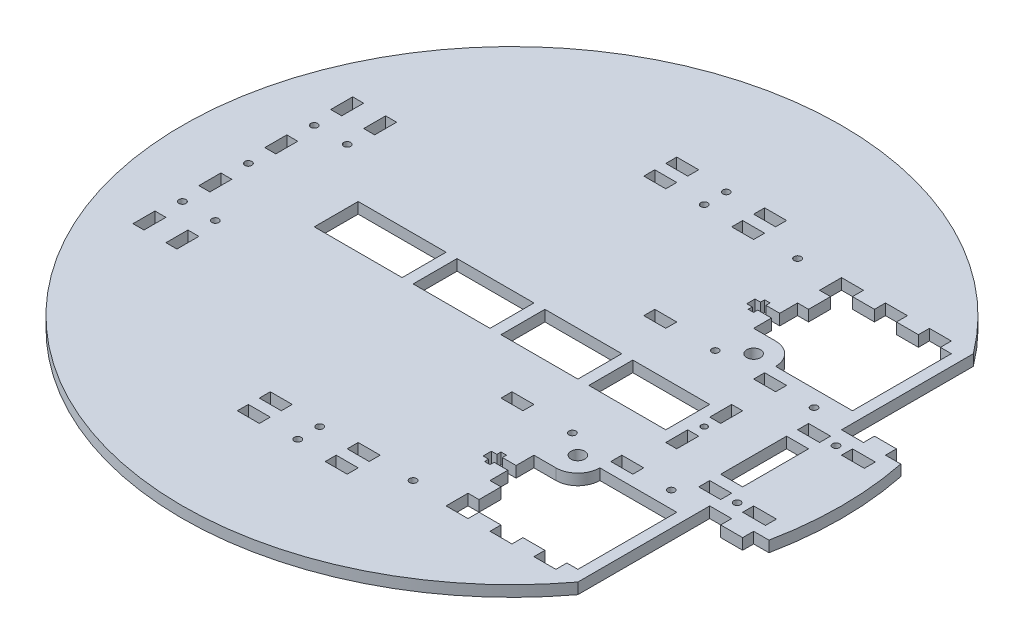
from build123d import *

# Parameters (mm, degrees)
SKETCH2_R           = 190.5
BOSS_EXTRUDE1_DEPTH = 6.35
SKETCH5_R           = 2
SKETCH5_R_2         = 2.032
SKETCH5_W           = 12.7
SKETCH5_H           = 6.35
CUT_EXTRUDE1_DEPTH  = 6.35
SKETCH6_R           = 2.032
SKETCH6_W           = 6.35
SKETCH6_H           = 12.7
CUT_EXTRUDE2_DEPTH  = 6.35
CUT_EXTRUDE3_START  = -6.35
SKETCH7_R           = 4.0005
CUT_EXTRUDE3_DEPTH  = 6.35
SKETCH11_R          = 2
SKETCH11_W          = 12.7
SKETCH11_H          = 6.35
CUT_EXTRUDE8_DEPTH  = 6.35
SKETCH12_R          = 2
SKETCH12_R_2        = 1.748762148
SKETCH12_W          = 12.7
SKETCH12_H          = 38.1
SKETCH12_H_2        = 6.35
SKETCH12_W_2        = 13.191185603
SKETCH12_W_3        = 6.35
SKETCH12_H_3        = 12.7
CUT_EXTRUDE9_DEPTH  = 6.35
CUT_EXTRUDE10_DEPTH = 6.35
SKETCH14_W          = 44.45
SKETCH14_H          = 25.4
SKETCH14_W_2        = 50.8
CUT_EXTRUDE12_DEPTH = 6.35
SKETCH6_3_R         = 2.032
SKETCH6_3_R_2       = 2
SKETCH6_3_W         = 6.35
SKETCH6_3_H         = 12.7
CUT_EXTRUDE13_DEPTH = 6.35
SKETCH17_R          = 2
SKETCH17_W          = 6.35
SKETCH17_H          = 12.7
CUT_EXTRUDE14_DEPTH = 6.35


with BuildPart() as part:
    # Sketch2 → Boss-Extrude1 (new body)
    with BuildSketch(Plane(origin=(0, 0, 0), x_dir=(1, 0, 0), z_dir=(0, 1, 0))):
        Circle(SKETCH2_R)
    extrude(amount=BOSS_EXTRUDE1_DEPTH)

    # Sketch5 → Cut-Extrude1 (cut)
    with BuildSketch(Plane(origin=(0, 6.35, 0), x_dir=(1, 0, 0), z_dir=(0, 1, 0))):
        with Locations((0, 123.825)):
            Circle(SKETCH5_R)
        with Locations((0, 111.125)):
            Circle(SKETCH5_R)
        with Locations((0, -111.125)):
            Circle(SKETCH5_R)
        with Locations((0, -123.825)):
            Circle(SKETCH5_R)
        with Locations((53.975, 111.125)):
            Circle(SKETCH5_R)
        with Locations((53.975, -111.125)):
            Circle(SKETCH5_R_2)
        with Locations((25.4, 111.125)):
            Rectangle(SKETCH5_W, SKETCH5_H)
        with Locations((25.4, 123.825)):
            Rectangle(SKETCH5_W, SKETCH5_H)
        with Locations((-25.4, 111.125)):
            Rectangle(SKETCH5_W, SKETCH5_H)
        with Locations((-25.4, 123.825)):
            Rectangle(SKETCH5_W, SKETCH5_H)
        with Locations((25.4, -111.125)):
            Rectangle(SKETCH5_W, SKETCH5_H)
        with Locations((-25.4, -111.125)):
            Rectangle(SKETCH5_W, SKETCH5_H)
        with Locations((-25.4, -123.825)):
            Rectangle(SKETCH5_W, SKETCH5_H)
        with Locations((25.4, -123.825)):
            Rectangle(SKETCH5_W, SKETCH5_H)
    extrude(amount=-CUT_EXTRUDE1_DEPTH, mode=Mode.SUBTRACT)

    # Sketch6 → Cut-Extrude2 (cut)
    with BuildSketch(Plane(origin=(0, 6.35, 0), x_dir=(1, 0, 0), z_dir=(0, 1, 0))):
        with Locations((-152.4, 0)):
            Circle(SKETCH6_R)
        with Locations((-152.4, 19.05)):
            Rectangle(SKETCH6_W, SKETCH6_H)
        with Locations((-152.4, -19.05)):
            Rectangle(SKETCH6_W, SKETCH6_H)
    extrude(amount=-CUT_EXTRUDE2_DEPTH, mode=Mode.SUBTRACT)

    # Sketch7 → Cut-Extrude3 (cut)
    with BuildSketch(Plane(origin=(0, 6.35, 0), x_dir=(1, 0, 0), z_dir=(0, 1, 0)).offset(CUT_EXTRUDE3_START)):
        with BuildLine():
            Line((146.05, -50.8), (101.6, -50.8))
            ThreePointArc((101.6, -50.8), (97.880256121, -59.780256121), (88.9, -63.5))
            Line((88.9, -63.5), (76.2, -63.5))
            Line((76.2, -63.5), (76.2, -88.9))
            Line((76.2, -88.9), (82.55, -88.9))
            Line((82.55, -88.9), (82.55, -101.6))
            Line((82.55, -101.6), (76.2, -101.6))
            Line((76.2, -101.6), (76.2, -114.3))
            Line((76.2, -114.3), (88.9, -114.3))
            Line((88.9, -114.3), (88.9, -107.95))
            Line((88.9, -107.95), (101.6, -107.95))
            Line((101.6, -107.95), (101.6, -114.3))
            Line((101.6, -114.3), (114.3, -114.3))
            Line((114.3, -114.3), (114.3, -107.95))
            Line((114.3, -107.95), (127, -107.95))
            Line((127, -107.95), (127, -114.3))
            Line((127, -114.3), (139.7, -114.3))
            Line((139.7, -114.3), (139.7, -107.95))
            Line((139.7, -107.95), (146.05, -107.95))
            Line((146.05, -107.95), (146.05, -50.8))
        make_face()
        with BuildLine():
            Line((152.4, 114.3), (152.4, 38.1))
            Line((152.4, 38.1), (165.1, 38.1))
            Line((165.1, 38.1), (165.1, 44.45))
            Line((165.1, 44.45), (177.8, 44.45))
            Line((177.8, 44.45), (177.8, 38.1))
            Line((177.8, 38.1), (186.6511184, 38.1))
            ThreePointArc((186.6511184, 38.1), (173.754209221, 78.10073481), (152.4, 114.3))
        make_face()
        with BuildLine():
            Line((152.4, -38.1), (152.4, -114.3))
            ThreePointArc((152.4, -114.3), (173.754209221, -78.10073481), (186.6511184, -38.1))
            Line((186.6511184, -38.1), (177.8, -38.1))
            Line((177.8, -38.1), (177.8, -44.45))
            Line((177.8, -44.45), (165.1, -44.45))
            Line((165.1, -44.45), (165.1, -38.1))
            Line((165.1, -38.1), (152.4, -38.1))
        make_face()
        with BuildLine():
            Line((88.9, 114.3), (76.2, 114.3))
            Line((76.2, 114.3), (76.2, 101.6))
            Line((76.2, 101.6), (82.55, 101.6))
            Line((82.55, 101.6), (82.55, 88.9))
            Line((82.55, 88.9), (76.2, 88.9))
            Line((76.2, 88.9), (76.2, 63.5))
            Line((76.2, 63.5), (88.9, 63.5))
            ThreePointArc((88.9, 63.5), (97.880256121, 59.780256121), (101.6, 50.8))
            Line((101.6, 50.8), (146.05, 50.8))
            Line((146.05, 50.8), (146.05, 107.95))
            Line((146.05, 107.95), (139.7, 107.95))
            Line((139.7, 107.95), (139.7, 114.3))
            Line((139.7, 114.3), (127, 114.3))
            Line((127, 114.3), (127, 107.95))
            Line((127, 107.95), (114.3, 107.95))
            Line((114.3, 107.95), (114.3, 114.3))
            Line((114.3, 114.3), (101.6, 114.3))
            Line((101.6, 114.3), (101.6, 107.95))
            Line((101.6, 107.95), (88.9, 107.95))
            Line((88.9, 107.95), (88.9, 114.3))
        make_face()
        with Locations((88.9, 50.8)):
            Circle(SKETCH7_R)
        with Locations((88.9, -50.8)):
            Circle(SKETCH7_R)
    extrude(amount=CUT_EXTRUDE3_DEPTH, mode=Mode.SUBTRACT)

    # Sketch11 → Cut-Extrude8 (cut)
    with BuildSketch(Plane(origin=(0, 6.35, 0), x_dir=(1, 0, 0), z_dir=(0, 1, 0))):
        with Locations((76.2, 41.275)):
            Circle(SKETCH11_R)
        with Locations((133.35, 41.275)):
            Circle(SKETCH11_R)
        with Locations((133.35, -41.275)):
            Circle(SKETCH11_R)
        with Locations((76.2, -41.275)):
            Circle(SKETCH11_R)
        with Locations((107.95, 41.275)):
            Rectangle(SKETCH11_W, SKETCH11_H)
        with Locations((44.45, 41.275)):
            Rectangle(SKETCH11_W, SKETCH11_H)
        with Locations((44.45, -41.275)):
            Rectangle(SKETCH11_W, SKETCH11_H)
        with Locations((107.95, -41.275)):
            Rectangle(SKETCH11_W, SKETCH11_H)
    extrude(amount=-CUT_EXTRUDE8_DEPTH, mode=Mode.SUBTRACT)

    # Sketch12 → Cut-Extrude9 (cut)
    with BuildSketch(Plane(origin=(0, 6.35, 0), x_dir=(1, 0, 0), z_dir=(0, 1, 0))):
        with Locations((158.75, 28.575)):
            Circle(SKETCH12_R)
        with Locations((158.75, -28.575)):
            Circle(SKETCH12_R)
        with Locations((111.125, 0)):
            Circle(SKETCH12_R_2)
        with Locations((146.05, 0)):
            Rectangle(SKETCH12_W, SKETCH12_H)
        with Locations((146.05, 28.575)):
            Rectangle(SKETCH12_W, SKETCH12_H_2)
        with Locations((171.695592802, -28.575)):
            Rectangle(SKETCH12_W_2, SKETCH12_H_2)
        with Locations((171.695592802, 28.575)):
            Rectangle(SKETCH12_W_2, SKETCH12_H_2)
        with Locations((146.05, -28.575)):
            Rectangle(SKETCH12_W, SKETCH12_H_2)
        with Locations((111.125, 12.7)):
            Rectangle(SKETCH12_W_3, SKETCH12_H_3)
        with Locations((111.125, -12.7)):
            Rectangle(SKETCH12_W_3, SKETCH12_H_3)
    extrude(amount=-CUT_EXTRUDE9_DEPTH, mode=Mode.SUBTRACT)

    # Sketch13 → Cut-Extrude10 (cut)
    with BuildSketch(Plane(origin=(0, 6.35, 0), x_dir=(1, 0, 0), z_dir=(0, 1, 0))):
        Polygon((65.0875, 73.81875), (65.0875, 71.4375), (68.2625, 71.4375), (68.2625, 73.81875), (76.2, 73.81875), (76.2, 78.58125), (68.2625, 78.58125), (68.2625, 80.9625), (65.0875, 80.9625), (65.0875, 78.58125), (61.9125, 78.58125), (61.9125, 73.81875), align=None)
        Polygon((76.2, -73.81875), (68.2625, -73.81875), (68.2625, -71.4375), (65.0875, -71.4375), (65.0875, -73.81875), (61.9125, -73.81875), (61.9125, -78.58125), (65.0875, -78.58125), (65.0875, -80.9625), (68.2625, -80.9625), (68.2625, -78.58125), (76.2, -78.58125), align=None)
    extrude(amount=-CUT_EXTRUDE10_DEPTH, mode=Mode.SUBTRACT)

    # Sketch14 → Cut-Extrude12 (cut)
    with BuildSketch(Plane(origin=(0, 6.35, 0), x_dir=(1, 0, 0), z_dir=(0, 1, 0))):
        with Locations((28.575, 0)):
            Rectangle(SKETCH14_W, SKETCH14_H)
        with Locations((-76.2, 0)):
            Rectangle(SKETCH14_W_2, SKETCH14_H)
        with Locations((79.375, 0)):
            Rectangle(SKETCH14_W, SKETCH14_H)
        with Locations((-22.225, 0)):
            Rectangle(SKETCH14_W, SKETCH14_H)
    extrude(amount=-CUT_EXTRUDE12_DEPTH, mode=Mode.SUBTRACT)

    # Sketch6_3 → Cut-Extrude13 (cut)
    with BuildSketch(Plane(origin=(0, 6.35, 0), x_dir=(1, 0, 0), z_dir=(0, 1, 0))):
        with Locations((-152.4, 0)):
            Circle(SKETCH6_3_R)
        with Locations((-152.4, 38.1)):
            Circle(SKETCH6_3_R_2)
        with Locations((-152.4, -38.1)):
            Circle(SKETCH6_3_R_2)
        with Locations((-152.4, 19.05)):
            Rectangle(SKETCH6_3_W, SKETCH6_3_H)
        with Locations((-152.4, -19.05)):
            Rectangle(SKETCH6_3_W, SKETCH6_3_H)
        with Locations((-152.4, -57.15)):
            Rectangle(SKETCH6_3_W, SKETCH6_3_H)
        with Locations((-152.4, 57.15)):
            Rectangle(SKETCH6_3_W, SKETCH6_3_H)
    extrude(amount=-CUT_EXTRUDE13_DEPTH, mode=Mode.SUBTRACT)

    # Sketch17 → Cut-Extrude14 (cut)
    with BuildSketch(Plane(origin=(0, 6.35, 0), x_dir=(1, 0, 0), z_dir=(0, 1, 0))):
        with Locations((-133.35, 38.1)):
            Circle(SKETCH17_R)
        with Locations((-133.35, -38.1)):
            Circle(SKETCH17_R)
        with Locations((-133.35, -57.15)):
            Rectangle(SKETCH17_W, SKETCH17_H)
        with Locations((-133.35, 57.15)):
            Rectangle(SKETCH17_W, SKETCH17_H)
    extrude(amount=-CUT_EXTRUDE14_DEPTH, mode=Mode.SUBTRACT)


solid = part.part
